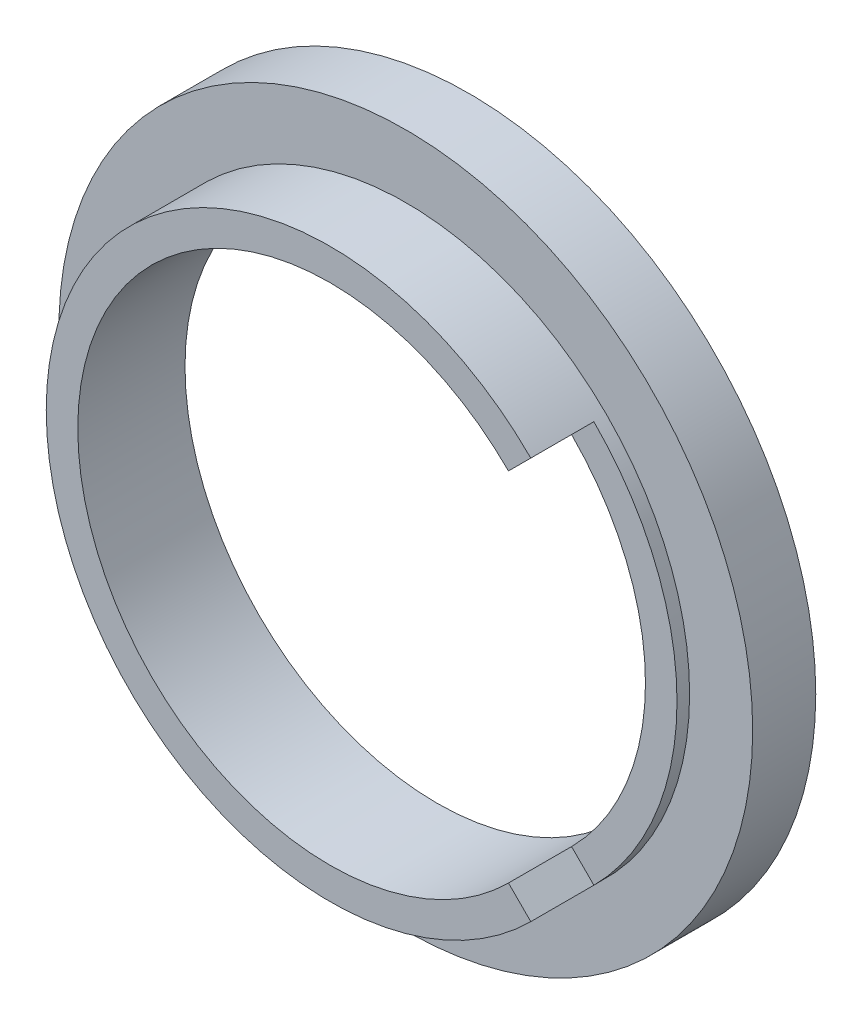
from build123d import *

# Parameters (mm, degrees)
SKETCH_1_R          = 11
EXTRUDE_1_DEPTH     = 2
SKETCH_2_R          = 9
EXTRUDE_2_DEPTH     = 2.4
SKETCH_3_R          = 10
CUT_EXTRUDE_1_DEPTH = 1
SKETCH_4_R          = 8
CUT_EXTRUDE_2_DEPTH = 10
CUT_EXTRUDE_3_DEPTH = 2


with BuildPart() as part:
    # 草图1 → 凸台-拉伸1 (new body)
    with BuildSketch(Plane.XY):
        Circle(SKETCH_1_R)
    extrude(amount=EXTRUDE_1_DEPTH)

    # 草图2 → 凸台-拉伸2 (add)
    with BuildSketch(Plane.XY.offset(2)):
        Circle(SKETCH_2_R)
    extrude(amount=EXTRUDE_2_DEPTH)

    # 草图3 → 切除-拉伸1 (cut)
    with BuildSketch(Plane(origin=(0, 0, 0), x_dir=(-1, 0, 0), z_dir=(0, 0, -1))):
        Circle(SKETCH_3_R)
    extrude(amount=-CUT_EXTRUDE_1_DEPTH, mode=Mode.SUBTRACT)

    # 草图4 → 切除-拉伸2 (cut)
    with BuildSketch(Plane(origin=(0, 0, 1), x_dir=(-1, 0, 0), z_dir=(0, 0, -1))):
        Circle(SKETCH_4_R)
    extrude(amount=-CUT_EXTRUDE_2_DEPTH, mode=Mode.SUBTRACT)

    # 草图5 → 切除-拉伸3 (cut)
    with BuildSketch(Plane.XY.offset(4.4)):
        with BuildLine():
            Line((0, 0), (6.363961031, 6.363961031))
            ThreePointArc((6.363961031, 6.363961031), (9, 0), (6.363961031, -6.363961031))
            Line((6.363961031, -6.363961031), (0, 0))
        make_face()
    extrude(amount=-CUT_EXTRUDE_3_DEPTH, mode=Mode.SUBTRACT)


solid = part.part
